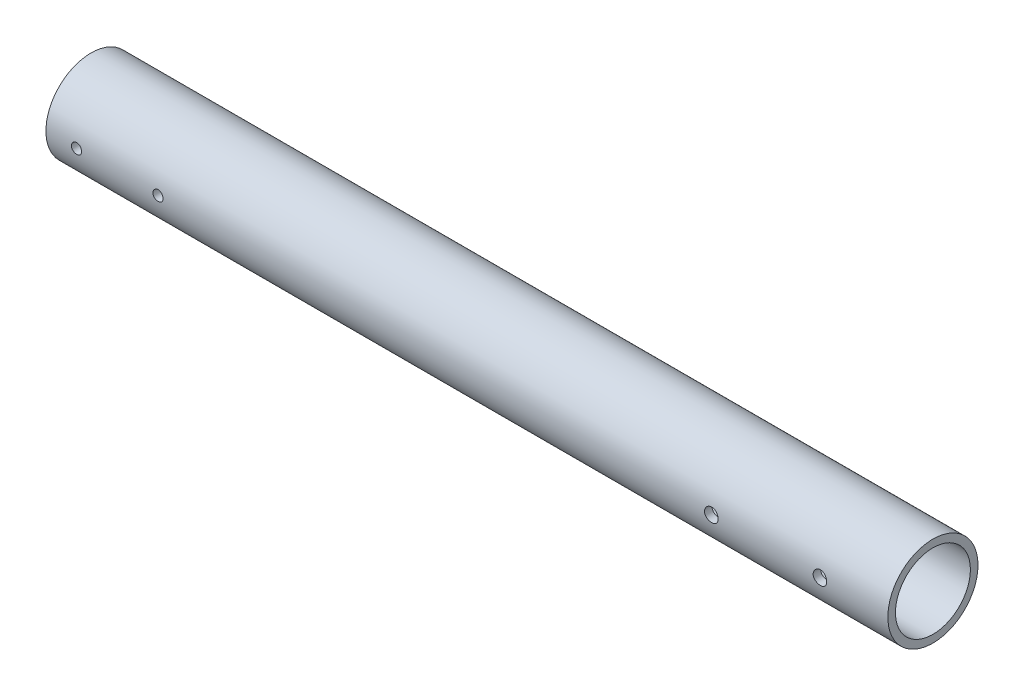
from build123d import *

# Parameters (mm, degrees)
BOSS_EXTRUDE1_DEPTH      = 196.85
BOSS_EXTRUDE1_DEPTH_BACK = 196.85
SKETCH1_R                = 21.082
SKETCH1_R_2              = 17.526
CUT_EXTRUDE1_DEPTH       = 200.095012363
CUT_EXTRUDE1_DEPTH_BACK  = 200.095012363
SKETCH2_R                = 2.38125
SKETCH3_R                = 3.175
CUT_EXTRUDE2_DEPTH       = 200.095012483


with BuildPart() as part:
    # Sketch1 → Boss-Extrude1 (new, two sides: drawn at the far end of the back side and taken through both)
    with BuildSketch(Plane(origin=(0, 0, 0), x_dir=(0, 0, -1), z_dir=(1, 0, 0)).offset(-BOSS_EXTRUDE1_DEPTH_BACK)):
        Circle(SKETCH1_R)
        Circle(SKETCH1_R_2, mode=Mode.SUBTRACT)
    extrude(amount=BOSS_EXTRUDE1_DEPTH + BOSS_EXTRUDE1_DEPTH_BACK)

    # Sketch2 → Cut-Extrude1 (cut, two sides: drawn at the far end of the back side and taken through both)
    with BuildSketch(Plane.XY.offset(-CUT_EXTRUDE1_DEPTH_BACK)):
        with Locations((-144.4625, 0)):
            Circle(SKETCH2_R)
        with Locations((-182.5625, 0)):
            Circle(SKETCH2_R)
    extrude(amount=CUT_EXTRUDE1_DEPTH + CUT_EXTRUDE1_DEPTH_BACK, mode=Mode.SUBTRACT)

    # Sketch3 → Cut-Extrude2 (cut, through all)
    with BuildSketch(Plane.XY):
        with Locations((165.1, 0)):
            Circle(SKETCH3_R)
        with Locations((114.3, 0)):
            Circle(SKETCH3_R)
    extrude(amount=CUT_EXTRUDE2_DEPTH, mode=Mode.SUBTRACT)


solid = part.part
